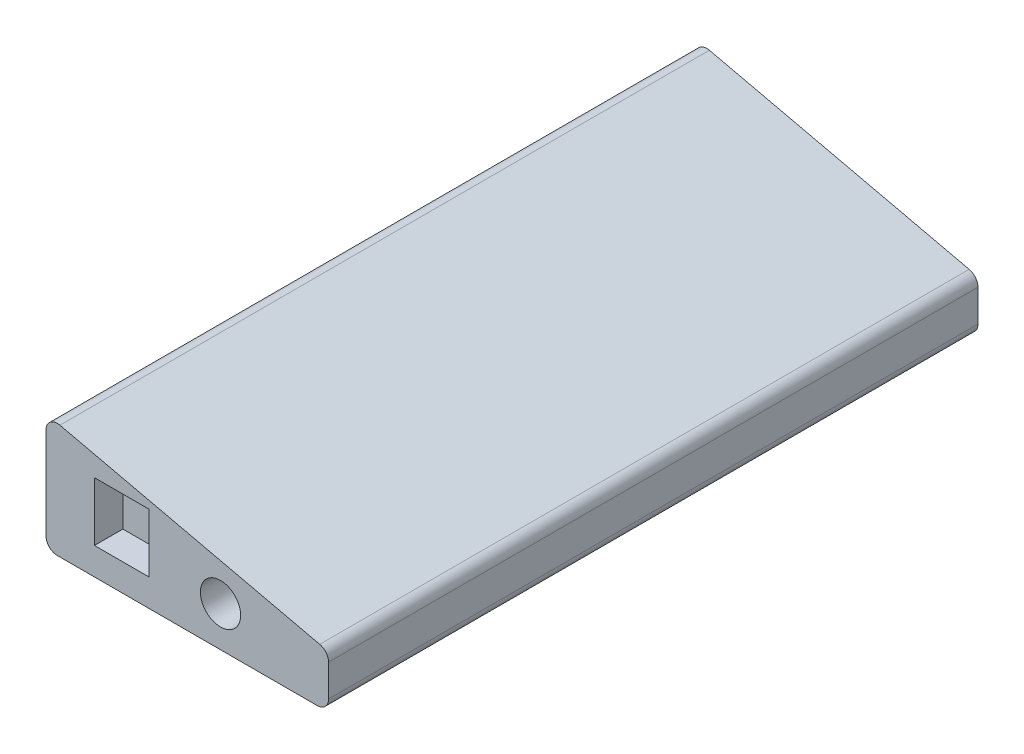
from build123d import *

# Parameters (mm, degrees)
BOSS_EXTRUDE1_DEPTH = 145.0848
SKETCH2_R           = 4.50215
SKETCH2_W           = 12.192
SKETCH2_H           = 13.1191
CUT_EXTRUDE1_DEPTH  = 6.35
SKETCH3_W           = 13.1064
SKETCH3_H           = 5.9944
CUT_EXTRUDE2_DEPTH  = 6.35
SKETCH4_W           = 13.0429
SKETCH4_H           = 5.9944
CUT_EXTRUDE3_DEPTH  = 6.35


with BuildPart() as part:
    # Sketch1 → Boss-Extrude1 (new body)
    with BuildSketch(Plane.XY):
        with BuildLine():
            Line((3.110233801, 25.508957203), (61.149233801, 12.137799255))
            ThreePointArc((61.149233801, 12.137799255), (62.566459918, 11.24428163), (63.119, 9.662635945))
            Line((63.119, 9.662635945), (63.119, 2.54))
            ThreePointArc((63.119, 2.54), (62.375051224, 0.743948776), (60.579, 0))
            Line((60.579, 0), (2.54, 0))
            ThreePointArc((2.54, 0), (0.743948776, 0.743948776), (0, 2.54))
            Line((0, 2.54), (0, 23.033793893))
            ThreePointArc((0, 23.033793893), (0.958354315, 25.021253811), (3.110233801, 25.508957203))
        make_face()
    extrude(amount=BOSS_EXTRUDE1_DEPTH)

    # Sketch2 → Cut-Extrude1 (cut)
    with BuildSketch(Plane.XY.offset(145.0848)):
        with Locations((38.989, 8.9154)):
            Circle(SKETCH2_R)
        with Locations((16.9164, 12.65555)):
            Rectangle(SKETCH2_W, SKETCH2_H)
    extrude(amount=-CUT_EXTRUDE1_DEPTH, mode=Mode.SUBTRACT)

    # Sketch3 → Cut-Extrude2 (cut)
    with BuildSketch(Plane.ZY):
        with Locations((31.9532, 10.1854)):
            Rectangle(SKETCH3_W, SKETCH3_H)
        with Locations((53.0352, 10.1854)):
            Rectangle(SKETCH3_W, SKETCH3_H)
        with Locations((74.1172, 10.1854)):
            Rectangle(SKETCH3_W, SKETCH3_H)
        with Locations((95.1992, 10.1854)):
            Rectangle(SKETCH3_W, SKETCH3_H)
        with Locations((116.2812, 10.1854)):
            Rectangle(SKETCH3_W, SKETCH3_H)
    extrude(amount=-CUT_EXTRUDE2_DEPTH, mode=Mode.SUBTRACT)

    # Sketch4 → Cut-Extrude3 (cut)
    with BuildSketch(Plane(origin=(0, 0, 0), x_dir=(-1, 0, 0), z_dir=(0, 0, -1))):
        with Locations((-13.68425, 10.1981)):
            Rectangle(SKETCH4_W, SKETCH4_H)
        with Locations((-35.02025, 10.1981)):
            Rectangle(SKETCH4_W, SKETCH4_H)
    extrude(amount=-CUT_EXTRUDE3_DEPTH, mode=Mode.SUBTRACT)


solid = part.part
